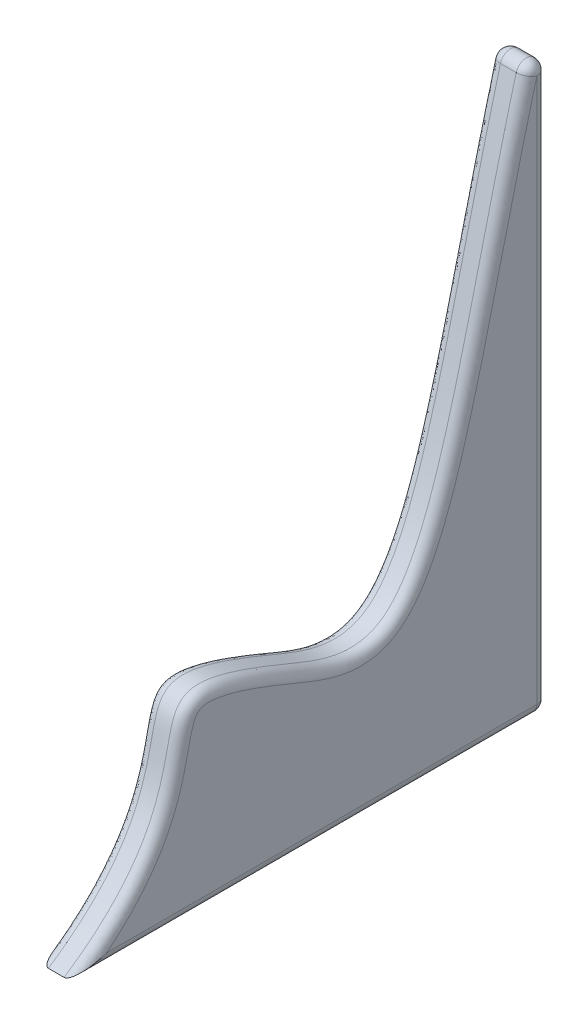
from build123d import *

# Parameters (mm, degrees)
BOSS_EXTRUDE1_DEPTH = 35
FILLET1_R           = 10


with BuildPart() as part:
    # Sketch1 → Boss-Extrude1 (new body)
    with BuildSketch(Plane(origin=(0, 0, 0), x_dir=(0, 0, -1), z_dir=(1, 0, 0))):
        with BuildLine():
            Line((200, 300), (200, -300))
            Line((200, -300), (-250, -300))
            add(Edge.make_bspline(
                [(-250, -300), (-77.059584902, -184.893065318), (-248.459152651, -52.24601151), (99.988368939, -208.314346462), (136.290182987, 88.168752174), (200, 300)],
                knots=[0, 0, 0, 0, 0.685015843, 0.785015843, 1, 1, 1, 1], degree=3))
        make_face()
    extrude(amount=BOSS_EXTRUDE1_DEPTH)

    # Fillet1
    fillet1_edges = [part.edges().sort_by_distance(p)[0] for p in [
        (35, -129.592059108, -75.193671806),
        (0, -129.592059108, -75.193671806),
        (0, -300, 25),
        (0, 0, -200),
        (35, 0, -200),
        (17.5, 300, -200),
        (17.5, -300, -200),
        (35, -300, 25),
    ]]
    fillet(fillet1_edges, radius=FILLET1_R)


solid = part.part
